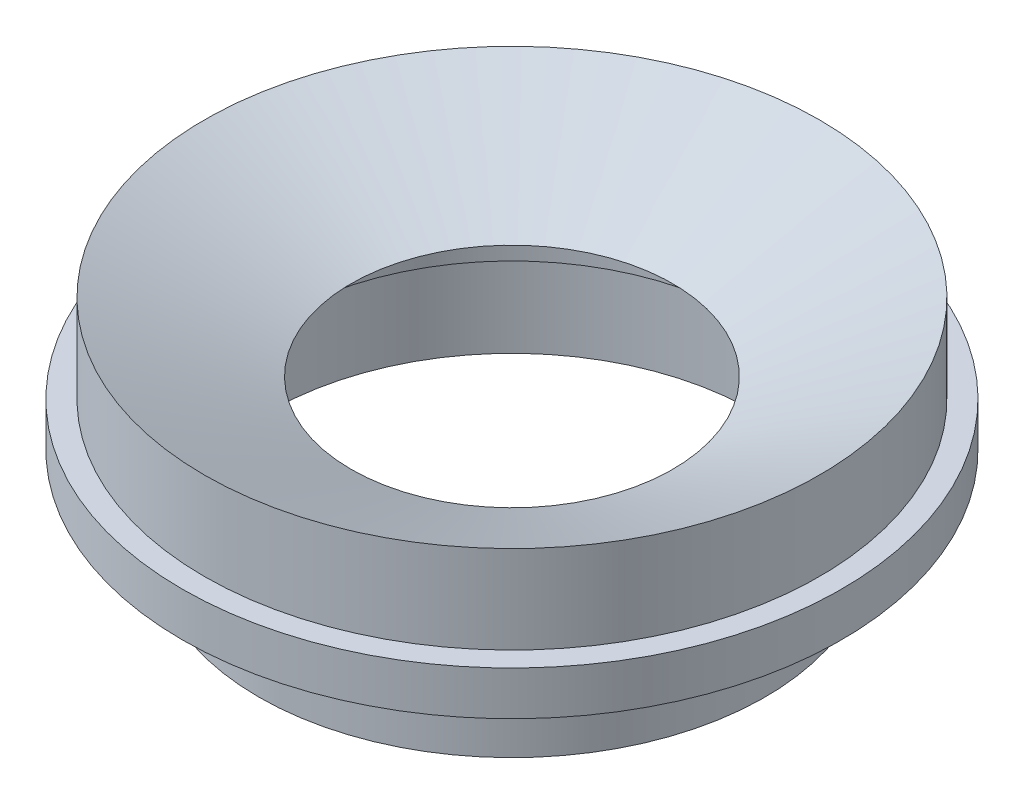
from build123d import *


with BuildPart() as part:
    # Sketch2 → Revolve1 (revolve)
    with BuildSketch(Plane.XY):
        Polygon((-66.802, 37.736346318), (-46.482, 37.736346318), (-88.9, 57.516184562), (-88.9, 32.116184562), (-95.25, 32.116184562), (-95.25, 19.416184562), (-73.152, 19.416184562), (-73.152, -5.949800563), (-69.977, -5.949800563), (-69.977, 19.416184562), (-66.802, 19.416184562), align=None)
    revolve(axis=Axis((0, 26.15468076, 0), (0, -1, 0)))


solid = part.part
